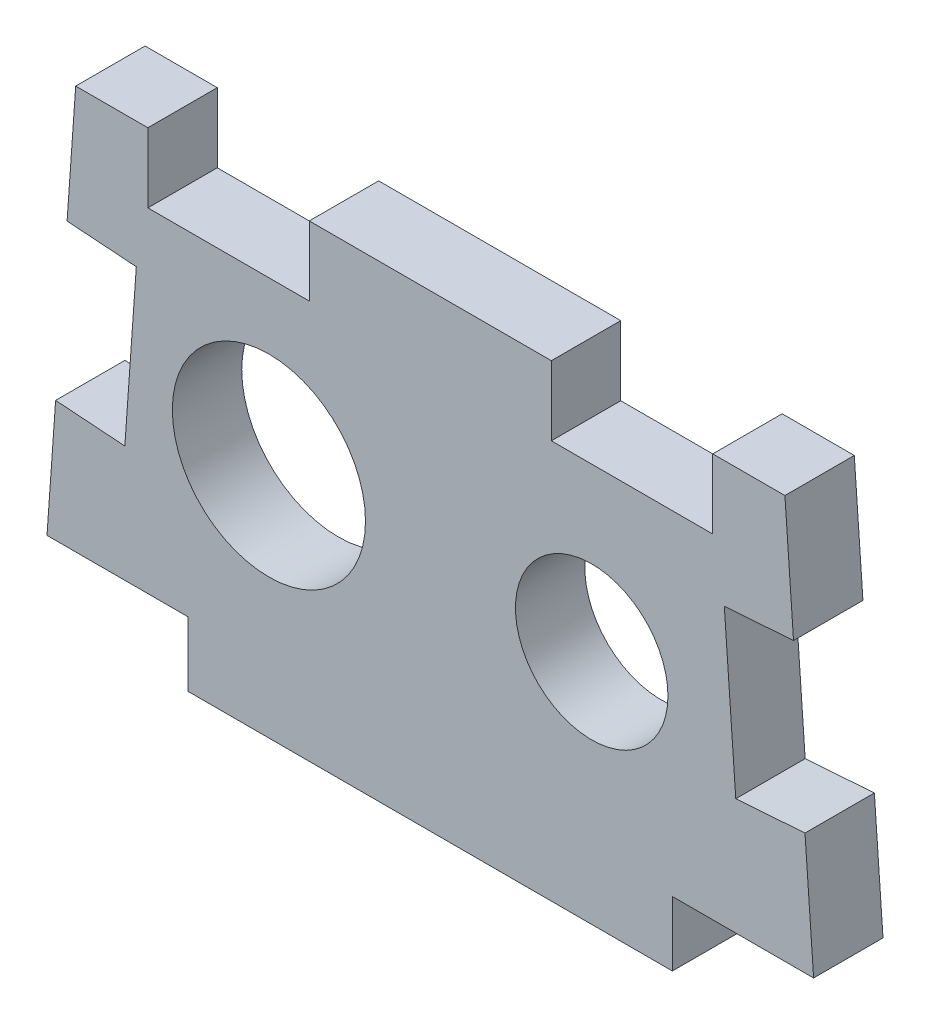
from build123d import *

# Parameters (mm, degrees)
SKETCH1_R           = 6
SKETCH1_R_2         = 7.6
BOSS_EXTRUDE1_DEPTH = 5.461
SKETCH2_W           = 12.7
SKETCH2_H           = 5.461
CUT_EXTRUDE1_DEPTH  = 6.461
SKETCH3_W           = 38.1
SKETCH3_H           = 5.08
BOSS_EXTRUDE2_DEPTH = 5.461


with BuildPart() as part:
    # Sketch1 → Boss-Extrude1 (new body)
    with BuildSketch(Plane.XY):
        Polygon((-27.903685016, 15.257451458), (27.903685016, 15.257451458), (30.1625, -16.492548542), (-30.1625, -16.492548542), align=None)
        with Locations((12.7, -3.00023153)):
            Circle(SKETCH1_R, mode=Mode.SUBTRACT)
        with Locations((-12.7, -3.00023153)):
            Circle(SKETCH1_R_2, mode=Mode.SUBTRACT)
    extrude(amount=BOSS_EXTRUDE1_DEPTH)

    # Sketch2 → Cut-Extrude1 (cut, through all)
    with BuildSketch(Plane.XY.offset(5.461)):
        with Locations((-15.875, 12.526951458)):
            Rectangle(SKETCH2_W, SKETCH2_H)
        with Locations((15.875, 12.526951458)):
            Rectangle(SKETCH2_W, SKETCH2_H)
        Polygon((-29.483716542, -6.951539225), (-28.582468475, 5.716442142), (-23.135236487, 5.328905473), (-24.036484554, -7.339075894), align=None)
        Polygon((28.582468475, 5.716442142), (29.483716542, -6.951539225), (24.036484554, -7.339075894), (23.135236487, 5.328905473), align=None)
    extrude(amount=-CUT_EXTRUDE1_DEPTH, mode=Mode.SUBTRACT)

    # Sketch3 → Boss-Extrude2 (add)
    with BuildSketch(Plane.XY.offset(5.461)):
        with Locations((0, -19.032548542)):
            Rectangle(SKETCH3_W, SKETCH3_H)
    extrude(amount=-BOSS_EXTRUDE2_DEPTH)


solid = part.part
